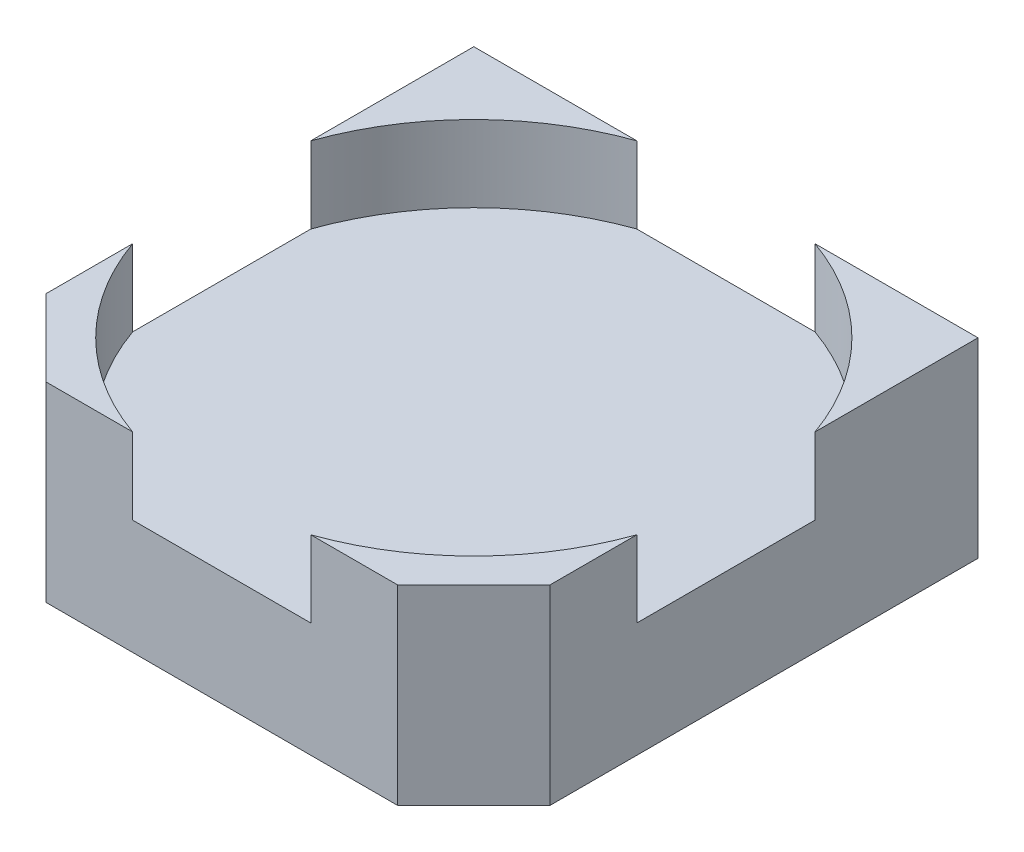
from build123d import *

# Parameters (mm, degrees)
SKETCH1_W           = 6.6
SKETCH1_H           = 6.6
BOSS_EXTRUDE1_DEPTH = 2.5
CHAMFER1_SIZE       = 1
SKETCH3_R           = 3.5
CUT_EXTRUDE1_DEPTH  = 1
CUT_EXTRUDE3_DEPTH  = 6.210875214


with BuildPart() as part:
    # Sketch1 → Boss-Extrude1 (new body)
    with BuildSketch(Plane(origin=(0, 0, 0), x_dir=(1, 0, 0), z_dir=(0, 1, 0))):
        Rectangle(SKETCH1_W, SKETCH1_H)
    extrude(amount=BOSS_EXTRUDE1_DEPTH)

    # Chamfer1
    chamfer1_edges = [part.edges().sort_by_distance(p)[0] for p in [
        (3.3, 1.25, 3.3),
        (-3.3, 1.25, 3.3),
    ]]
    chamfer(chamfer1_edges, length=CHAMFER1_SIZE)

    # Sketch3 → Cut-Extrude1 (cut)
    with BuildSketch(Plane(origin=(0, 2.5, 0), x_dir=(1, 0, 0), z_dir=(0, 1, 0))):
        Circle(SKETCH3_R)
    extrude(amount=-CUT_EXTRUDE1_DEPTH, mode=Mode.SUBTRACT)

    # Sketch6 → Cut-Extrude3 (cut, through all)
    with BuildSketch(Plane(origin=(0, 0.19926807, -0.012076853), x_dir=(1, 0, 0), z_dir=(0, 0.9981684966311909, -0.060495060401890365))):
        with BuildLine():
            Line((-0.45, 3.293956039), (-0.45, 1.097985346))
            add(Edge.make_bspline(
                [(-0.45, 1.097985346), (-0.45, 0.648809523), (0, 0.648809523), (0.45, 0.648809523), (0.45, 1.097985346)],
                knots=[3.141592654, 3.141592654, 3.141592654, 4.71238898, 4.71238898, 6.283185307, 6.283185307, 6.283185307], degree=2, weights=[1, 0.707106781, 1, 0.707106781, 1]))
            Line((0.45, 1.097985346), (0.45, 3.293956039))
            Line((0.45, 3.293956039), (-0.45, 3.293956039))
        make_face()
    cut_extrude3 = extrude(amount=-CUT_EXTRUDE3_DEPTH, mode=Mode.SUBTRACT)

    # Mirror1: Cut-Extrude3 across plane
    add(cut_extrude3.mirror(Plane.XY), mode=Mode.SUBTRACT)


solid = part.part
